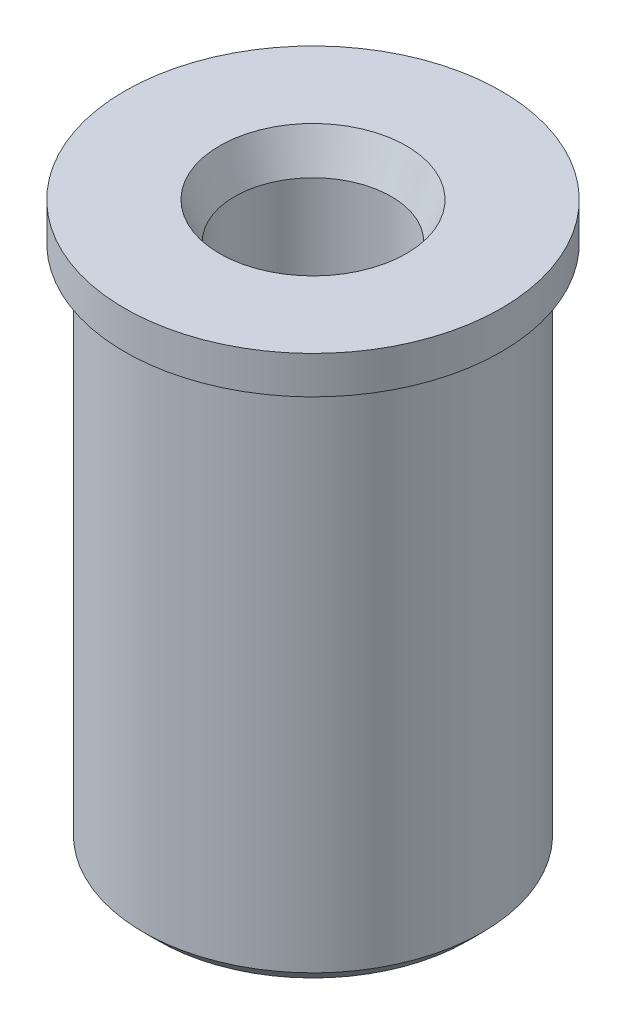
from build123d import *


with BuildPart() as part:
    # Sketch1 one side → Revolve1 (revolve)
    with BuildSketch(Plane.XY, mode=Mode.PRIVATE) as revolve1_sk:
        Polygon((0, -3.175), (0, 6.35), (-3.175, 6.35), (-3.175, 5.715), (-2.8575, 5.715), (-2.8575, -2.921), (-2.6035, -3.175), align=None)
    revolve(revolve1_sk.sketch.rotate(Axis((0, 0, 0), (0, 1, 0)), 180), axis=Axis((0, 0, 0), (0, 1, 0)))  # turned: the seam where the file's is

    # Sketch2 → #6-80 Tapped Hole1 (revolve, cut)
    with BuildSketch(Plane(origin=(0, 6.35, 0), x_dir=(0, 0, 1), z_dir=(1, 0, 0))):
        Polygon((0, 0), (0, 9.525), (1.5748, 9.525), (1.3208, 8.911789755), (1.3208, 0.613210245), (1.5748, 0), align=None)
    revolve(axis=Axis((0, 12.7, 0), (0, -1, 0)), mode=Mode.SUBTRACT)


solid = part.part
